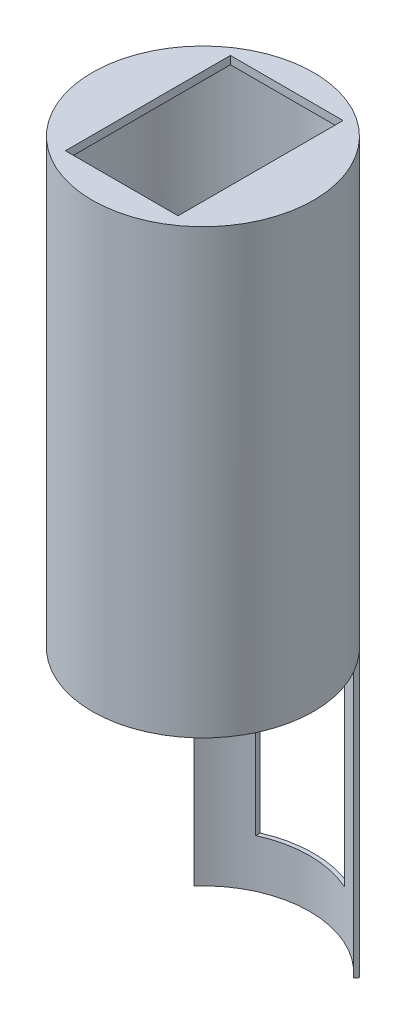
from build123d import *

# Parameters (mm, degrees)
SKETCH_1_R               = 27.5
EXTRUDE_1_DEPTH          = 110
EXTRUDE_1_DEPTH_BACK     = 70
SKETCH_2_R               = 26.5
CUT_EXTRUDE_1_DEPTH      = 108
CUT_EXTRUDE_1_DEPTH_BACK = 70
CUT_EXTRUDE_6_DEPTH      = 70
SKETCH_7_W               = 22
SKETCH_7_H               = 20
CUT_EXTRUDE_7_DEPTH      = 48
SKETCH_8_W               = 28
SKETCH_8_H               = 41
CUT_EXTRUDE_8_DEPTH      = 119


with BuildPart() as part:
    # 草圖1 → 填料-伸長1 (new body, two sides)
    with BuildSketch(Plane(origin=(0, 0, 0), x_dir=(1, 0, 0), z_dir=(0, 1, 0))) as extrude_1_sk:
        Circle(SKETCH_1_R)
    extrude(amount=EXTRUDE_1_DEPTH)
    extrude(extrude_1_sk.sketch, amount=-EXTRUDE_1_DEPTH_BACK)

    # 草圖2 → 除料-伸長1 (cut, two sides)
    with BuildSketch(Plane(origin=(0, 0, 0), x_dir=(1, 0, 0), z_dir=(0, 1, 0))) as cut_extrude_1_sk:
        Circle(SKETCH_2_R)
    extrude(amount=CUT_EXTRUDE_1_DEPTH, mode=Mode.SUBTRACT)
    extrude(cut_extrude_1_sk.sketch, amount=-CUT_EXTRUDE_1_DEPTH_BACK, mode=Mode.SUBTRACT)

    # 草圖6 → 除料-伸長6 (cut)
    with BuildSketch(Plane(origin=(0, 0, 0), x_dir=(1, 0, 0), z_dir=(0, 1, 0))):
        with BuildLine():
            Line((-26.5, 0), (26.300758937, 0))
            Line((26.300758937, 0), (26.5, 0))
            ThreePointArc((26.5, 0), (24.766835815, 9.426231681), (19.794049532, 17.619466595))
            Line((19.794049532, 17.619466595), (20.446397381, 18.390074337))
            ThreePointArc((20.446397381, 18.390074337), (25.676116607, 9.848199633), (27.5, 0))
            ThreePointArc((27.5, 0), (0, -27.5), (-27.5, 0))
            ThreePointArc((-27.5, 0), (-25.676116607, 9.848199633), (-20.446397381, 18.390074337))
            Line((-20.446397381, 18.390074337), (-19.794049532, 17.619466595))
            ThreePointArc((-19.794049532, 17.619466595), (-24.766835815, 9.426231681), (-26.5, 0))
        make_face()
    extrude(amount=-CUT_EXTRUDE_6_DEPTH, mode=Mode.SUBTRACT)

    # 草圖7 → 除料-伸長7 (cut)
    with BuildSketch(Plane(origin=(0, -10, 0), x_dir=(1, 0, 0), z_dir=(0, 1, 0))):
        with Locations((0, 27.910624132)):
            Rectangle(SKETCH_7_W, SKETCH_7_H)
    extrude(amount=-CUT_EXTRUDE_7_DEPTH, mode=Mode.SUBTRACT)

    # 草圖8 → 除料-伸長8 (cut)
    with BuildSketch(Plane(origin=(0, 0, 0), x_dir=(1, 0, 0), z_dir=(0, 1, 0))):
        with Locations((0, 0.320473431)):
            Rectangle(SKETCH_8_W, SKETCH_8_H)
    extrude(amount=CUT_EXTRUDE_8_DEPTH, mode=Mode.SUBTRACT)


solid = part.part
